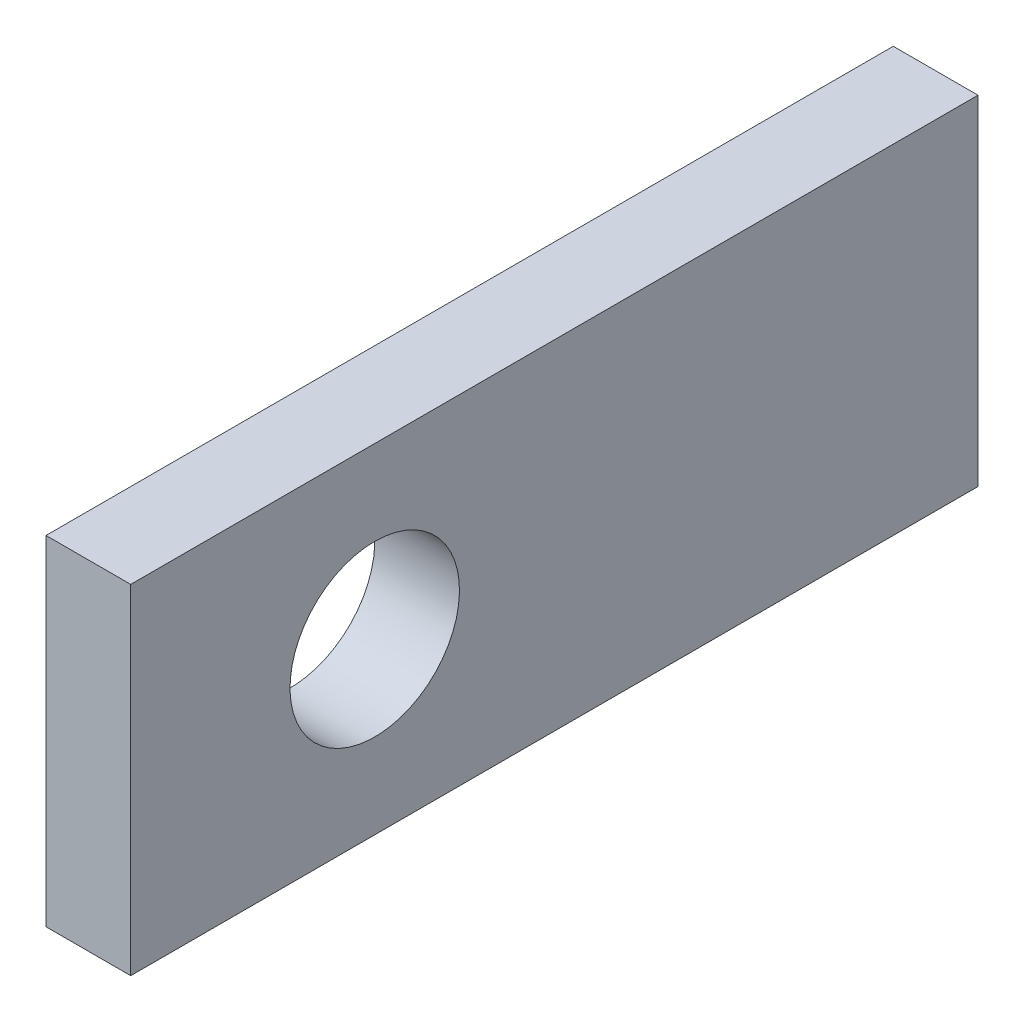
from build123d import *

# Parameters (mm, degrees)
SKETCH1_W           = 3.175
SKETCH1_H           = 12.7
BOSS_EXTRUDE1_DEPTH = 31.75
SKETCH2_R           = 3.175
CUT_EXTRUDE1_DEPTH  = 4.175


with BuildPart() as part:
    # Sketch1 → Boss-Extrude1 (new body)
    with BuildSketch(Plane.XY):
        with Locations((33.498717245, 1.154052784)):
            Rectangle(SKETCH1_W, SKETCH1_H)
    extrude(amount=BOSS_EXTRUDE1_DEPTH)

    # Sketch2 → Cut-Extrude1 (cut, through all)
    with BuildSketch(Plane(origin=(35.086217245, 0, 0), x_dir=(0, 0, -1), z_dir=(1, 0, 0))):
        with Locations((-22.606, 1.154052784)):
            Circle(SKETCH2_R)
    extrude(amount=-CUT_EXTRUDE1_DEPTH, mode=Mode.SUBTRACT)


solid = part.part
